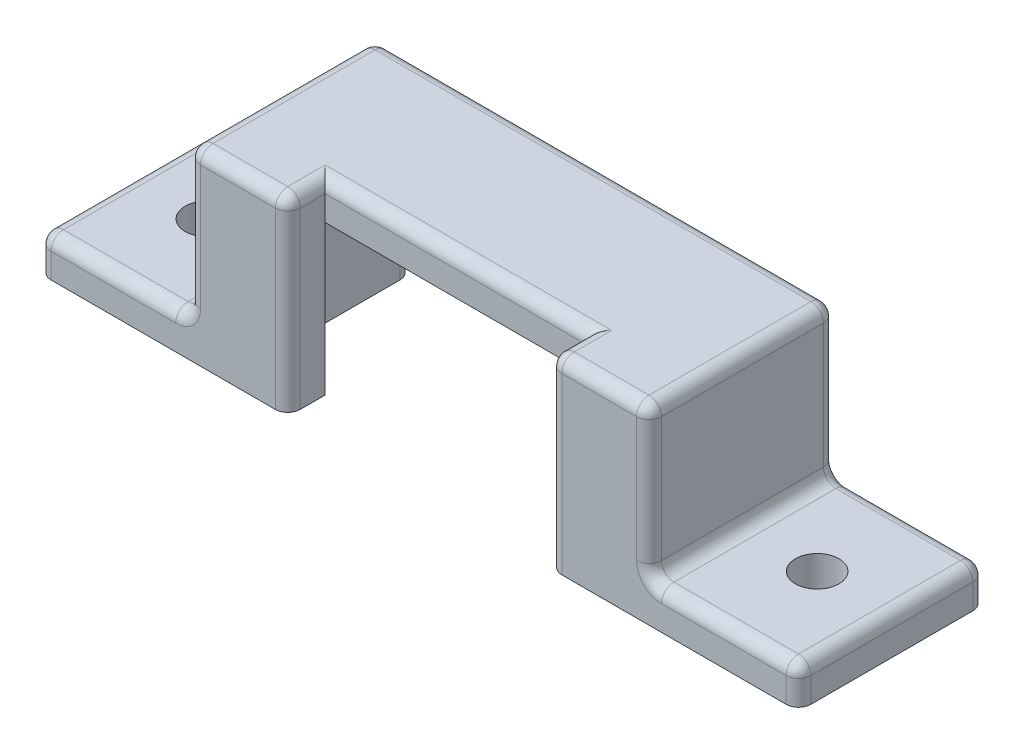
from build123d import *

# Parameters (mm, degrees)
BOSS_EXTRUDE1_DEPTH = 12
BOSS_EXTRUDE2_DEPTH = 3
FILLET1_R           = 1
SKETCH3_R           = 1.75
CUT_EXTRUDE2_DEPTH  = 3


with BuildPart() as part:
    # Sketch1 → Boss-Extrude1 (new body)
    with BuildSketch(Plane.XY):
        Polygon((-30.5, 3), (-18.5, 3), (-18.5, 15), (18.5, 15), (18.5, 3), (30.5, 3), (30.5, 0), (15.5, 0), (15.5, 12), (-15.5, 12), (-15.5, 0), (-30.5, 0), align=None)
    extrude(amount=-BOSS_EXTRUDE1_DEPTH)

    # Sketch2 → Boss-Extrude2 (add)
    with BuildSketch(Plane.XY):
        Polygon((-18.5, 15), (-10.5, 15), (-10.5, 0), (-30.5, 0), (-30.5, 3), (-18.5, 3), align=None)
        Polygon((30.5, 0), (10.5, 0), (10.5, 15), (18.5, 15), (18.5, 3), (30.5, 3), align=None)
    extrude(amount=BOSS_EXTRUDE2_DEPTH)

    # Fillet1
    fillet1_edges = [part.edges().sort_by_distance(p)[0] for p in [
        (-15.5, 6, -12),
        (-30.5, 3, -4.5),
        (-18.5, 3, -4.5),
        (-18.5, 15, -4.5),
        (15.5, 6, -12),
        (18.5, 15, -4.5),
        (18.5, 3, -4.5),
        (30.5, 3, -4.5),
        (30.5, 1.5, -12),
        (24.5, 3, -12),
        (18.5, 9, -12),
        (-10.5, 15, 1.5),
        (-18.5, 9, 3),
        (-24.5, 3, 3),
        (-30.5, 1.5, 3),
        (-10.5, 7.5, 3),
        (-14.5, 15, 3),
        (0, 15, -12),
        (-18.5, 9, -12),
        (-24.5, 3, -12),
        (-30.5, 1.5, -12),
        (0, 15, 0),
        (10.5, 15, 1.5),
        (30.5, 1.5, 3),
        (24.5, 3, 3),
        (18.5, 9, 3),
        (14.5, 15, 3),
        (10.5, 7.5, 3),
    ]]
    fillet(fillet1_edges, radius=FILLET1_R)

    # Sketch3 → Cut-Extrude2 (cut)
    with BuildSketch(Plane(origin=(0, 3, 0), x_dir=(1, 0, 0), z_dir=(0, 1, 0))):
        with Locations((-24.5, 4.5)):
            Circle(SKETCH3_R)
        with Locations((24.5, 4.5)):
            Circle(SKETCH3_R)
    extrude(amount=-CUT_EXTRUDE2_DEPTH, mode=Mode.SUBTRACT)


solid = part.part
